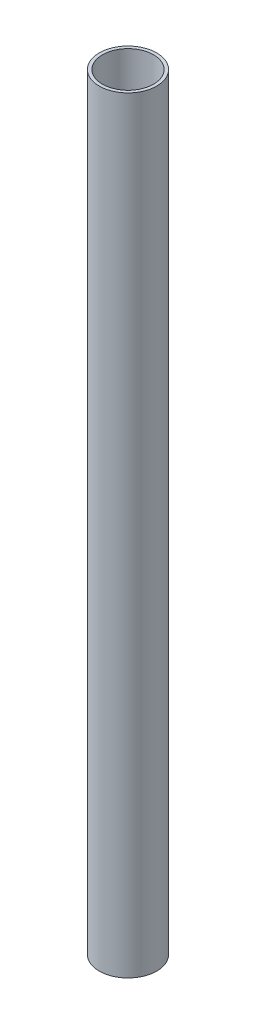
from build123d import *

# Parameters (mm, degrees)
SKETCH1_R           = 57.15
SKETCH1_R_2         = 50.8
BOSS_EXTRUDE1_DEPTH = 1524


with BuildPart() as part:
    # Sketch1 → Boss-Extrude1 (new body)
    with BuildSketch(Plane(origin=(0, 0, 0), x_dir=(1, 0, 0), z_dir=(0, 1, 0))):
        Circle(SKETCH1_R)
        Circle(SKETCH1_R_2, mode=Mode.SUBTRACT)
    extrude(amount=BOSS_EXTRUDE1_DEPTH)


solid = part.part
